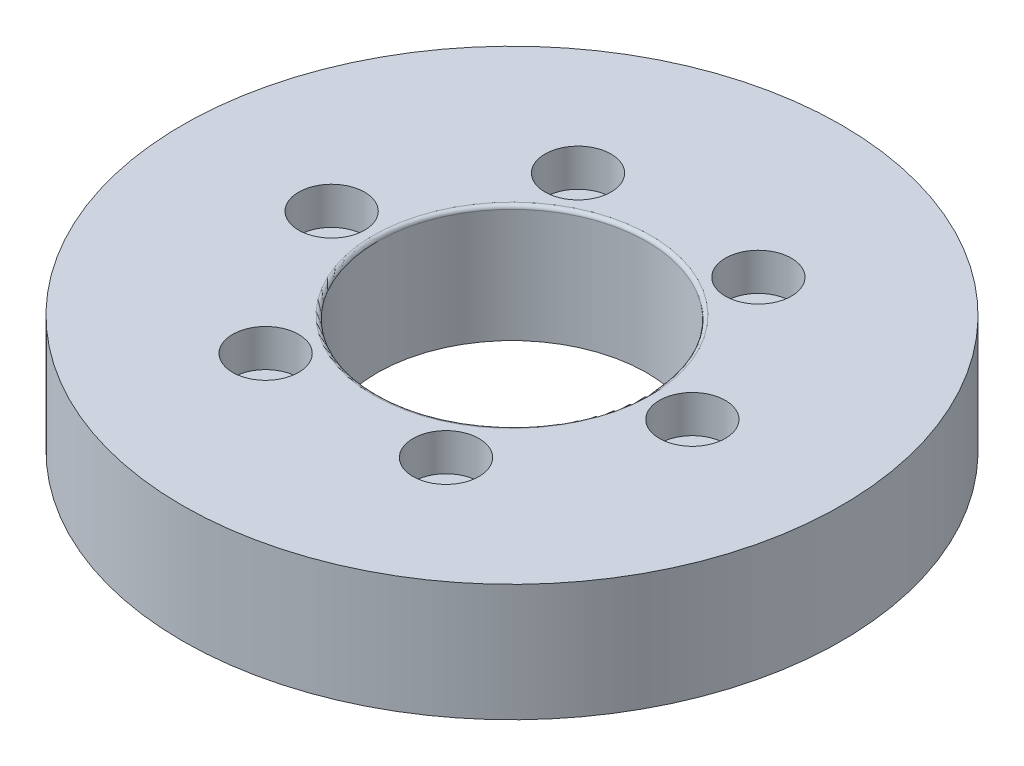
from build123d import *

# Parameters (mm, degrees)
SKETCH_1_R               = 44.95
SKETCH_1_R_2             = 2.5
SKETCH_1_R_3             = 18.4
EXTRUDE_1_DEPTH          = 16
SKETCH_2_R               = 4
CUT_EXTRUDE_1_DEPTH      = 3
SKETCH_4_R               = 4.5
CUT_EXTRUDE_2_DEPTH      = 5.1
SKETCH_5_R               = 1.5
CUT_EXTRUDE_3_DEPTH      = 10
PATTERN_CIRCULAR_1_COUNT = 12
FILLET_1_R               = 0.5


with BuildPart() as part:
    # 草图1 → 凸台-拉伸1 (new body)
    with BuildSketch(Plane(origin=(0, 0, 0), x_dir=(1, 0, 0), z_dir=(0, 1, 0))):
        Circle(SKETCH_1_R)
        with Locations((-24.6, 0)):
            Circle(SKETCH_1_R_2, mode=Mode.SUBTRACT)
        with Locations((-12.3, 21.304224933)):
            Circle(SKETCH_1_R_2, mode=Mode.SUBTRACT)
        with Locations((12.3, 21.304224933)):
            Circle(SKETCH_1_R_2, mode=Mode.SUBTRACT)
        with Locations((24.6, 0)):
            Circle(SKETCH_1_R_2, mode=Mode.SUBTRACT)
        with Locations((12.3, -21.304224933)):
            Circle(SKETCH_1_R_2, mode=Mode.SUBTRACT)
        with Locations((-12.3, -21.304224933)):
            Circle(SKETCH_1_R_2, mode=Mode.SUBTRACT)
        Circle(SKETCH_1_R_3, mode=Mode.SUBTRACT)
    extrude(amount=EXTRUDE_1_DEPTH)

    # 草图2 → 切除-拉伸1 (cut)
    with BuildSketch(Plane.XZ):
        with Locations((-21.304224933, -12.3)):
            Circle(SKETCH_2_R)
        with Locations((0, 24.6)):
            Circle(SKETCH_2_R)
        with Locations((21.304224933, -12.3)):
            Circle(SKETCH_2_R)
    extrude(amount=-CUT_EXTRUDE_1_DEPTH, mode=Mode.SUBTRACT)

    # 草图4 → 切除-拉伸2 (cut)
    with BuildSketch(Plane(origin=(0, 16, 0), x_dir=(1, 0, 0), z_dir=(0, 1, 0))):
        with Locations((-24.6, 0)):
            Circle(SKETCH_4_R)
        with Locations((-12.3, 21.304224933)):
            Circle(SKETCH_4_R)
        with Locations((12.3, 21.304224933)):
            Circle(SKETCH_4_R)
        with Locations((24.6, 0)):
            Circle(SKETCH_4_R)
        with Locations((12.3, -21.304224933)):
            Circle(SKETCH_4_R)
        with Locations((-12.3, -21.304224933)):
            Circle(SKETCH_4_R)
    extrude(amount=-CUT_EXTRUDE_2_DEPTH, mode=Mode.SUBTRACT)

    # 草图5 → 切除-拉伸3 (cut)
    with BuildSketch(Plane(origin=(43, 0, 0), x_dir=(0, 0, -1), z_dir=(1, 0, 0))):
        with Locations((0, 12)):
            Circle(SKETCH_5_R)
    cut_extrude_3 = extrude(amount=-CUT_EXTRUDE_3_DEPTH, mode=Mode.SUBTRACT)

    # 阵列(圆周)1: 切除-拉伸3 ×12 about axis
    pattern_circular_1_axis = Axis((0, 0, 0), (0, 1, 0))
    for i in range(1, PATTERN_CIRCULAR_1_COUNT):
        add(cut_extrude_3.rotate(pattern_circular_1_axis, i * 360 / PATTERN_CIRCULAR_1_COUNT), mode=Mode.SUBTRACT)

    # 圆角1
    fillet_1_edges = [part.edges().sort_by_distance(p)[0] for p in [
        (-18.4, 16, 0),
    ]]
    fillet(fillet_1_edges, radius=FILLET_1_R)


solid = part.part
